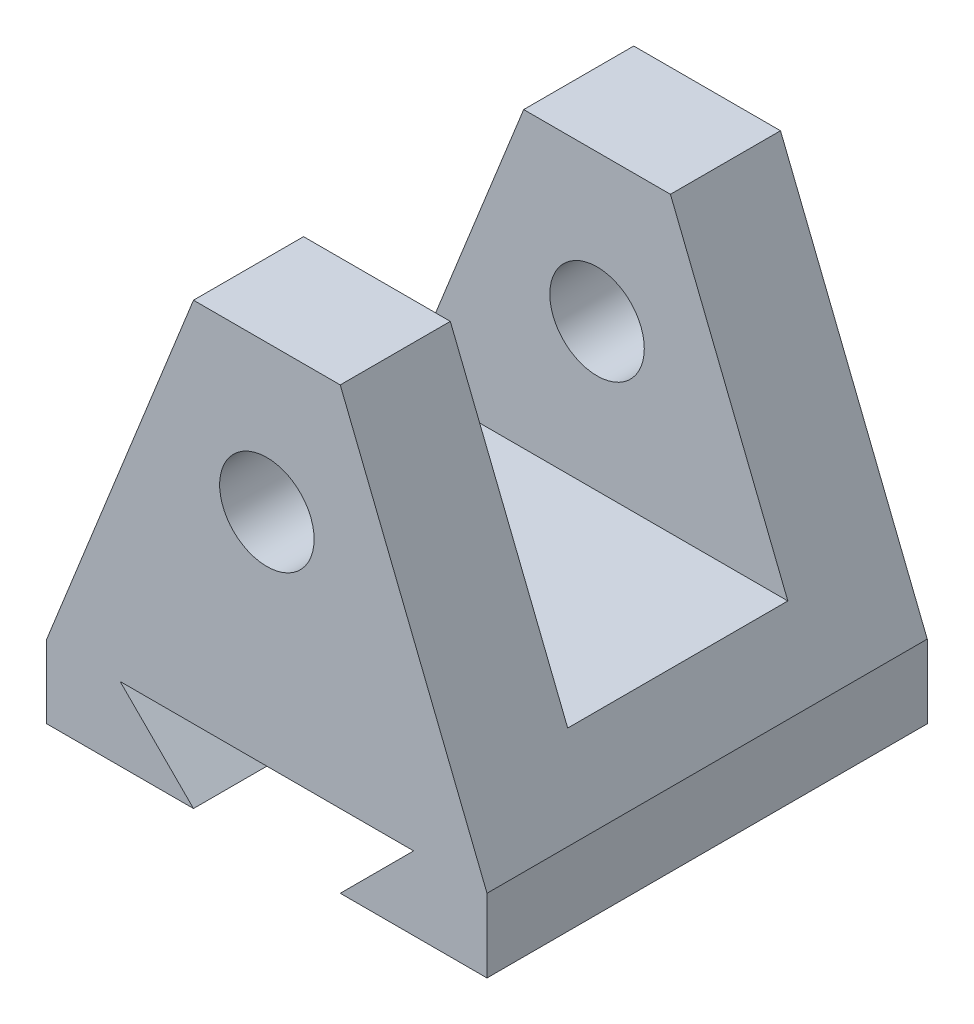
from build123d import *

# Parameters (mm, degrees)
BOSS_EXTRUDE1_DEPTH = 60
SKETCH3_R           = 6.436223385
CUT_EXTRUDE1_DEPTH  = 84.666002653
SKETCH9_W           = 30
SKETCH9_H           = 40
CUT_EXTRUDE3_DEPTH  = 99.488578018


with BuildPart() as part:
    # Sketch2 → Boss-Extrude1 (new body)
    with BuildSketch(Plane.XY):
        Polygon((-30, -10), (-30, 0), (-10, 50), (10, 50), (30, 0), (30, -10), (10, -10), (20, 0), (-20, 0), (-10, -10), align=None)
    extrude(amount=BOSS_EXTRUDE1_DEPTH)

    # Sketch3 → Cut-Extrude1 (cut, through all)
    with BuildSketch(Plane.XY.offset(60)):
        with Locations((0, 30)):
            Circle(SKETCH3_R)
    extrude(amount=-CUT_EXTRUDE1_DEPTH, mode=Mode.SUBTRACT)

    # Sketch9 → Cut-Extrude3 (cut, through all)
    with BuildSketch(Plane(origin=(30, 0, 0), x_dir=(0, 0, -1), z_dir=(1, 0, 0))):
        with Locations((-30, 30)):
            Rectangle(SKETCH9_W, SKETCH9_H)
    extrude(amount=-CUT_EXTRUDE3_DEPTH, mode=Mode.SUBTRACT)


solid = part.part
